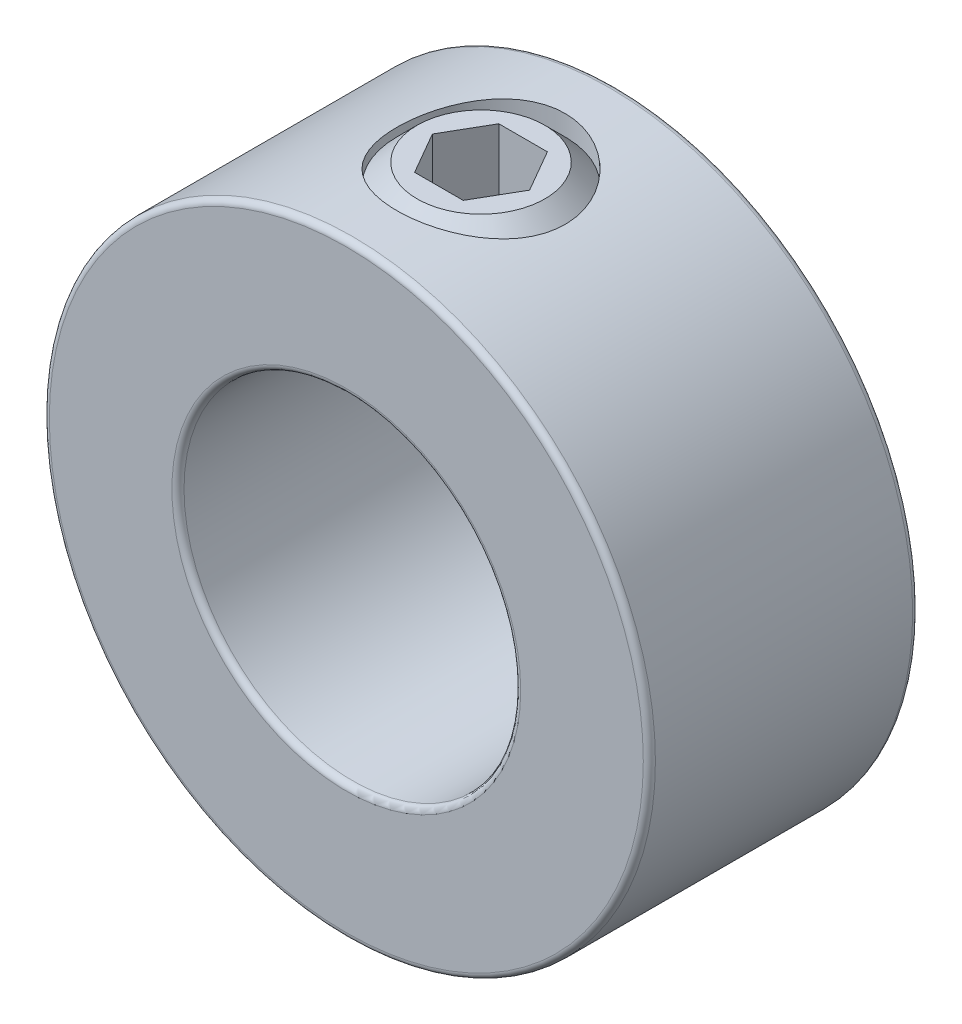
from build123d import *

# Parameters (mm, degrees)
SKETCH1_R          = 14.2875
SKETCH1_R_2        = 7.9375
EXTRUDE1_DEPTH     = 6.35
SKETCH2_R          = 3.96875
CUT_EXTRUDE1_DEPTH = 15.2875
FILLET1_R          = 0.28575
CUT_EXTRUDE2_DEPTH = 3.96875


with BuildPart() as part:
    # Sketch1 → Extrude1 (new body, symmetric)
    with BuildSketch(Plane.XY):
        Circle(SKETCH1_R)
        Circle(SKETCH1_R_2, mode=Mode.SUBTRACT)
    extrude(amount=EXTRUDE1_DEPTH, both=True)

    # Sketch2 → Cut-Extrude1 (cut, through all)
    with BuildSketch(Plane(origin=(41.275, 0, 0), x_dir=(0, 0, -1), z_dir=(0, -1, 0))):
        with Locations((0, -41.275)):
            Circle(SKETCH2_R)
    extrude(amount=-CUT_EXTRUDE1_DEPTH, mode=Mode.SUBTRACT)

    # Fillet1
    fillet1_edges = [part.edges().sort_by_distance(p)[0] for p in [
        (-14.2875, 0, -6.35),
        (-14.2875, 0, 6.35),
        (-7.9375, 0, -6.35),
        (-7.9375, 0, 6.35),
    ]]
    fillet(fillet1_edges, radius=FILLET1_R)


with BuildPart() as body_2:
    # Sketch3 → Revolve1 (revolve)
    with BuildSketch(Plane.XY):
        Polygon((-3.010240789, 7.9375), (-1.150211053, 7.9375), (0, 9.087711053), (0, 14.2875), (-3.010240789, 14.2875), (-3.96875, 13.328990789), (-3.96875, 8.896009211), align=None)
    revolve(axis=Axis((0, 7.9375, 0), (0, -1, 0)))

    # Sketch4 → Cut-Extrude2 (cut)
    with BuildSketch(Plane(origin=(3.3734375, 14.2875, 0), x_dir=(0, 0, -1), z_dir=(0, -1, 0))):
        Polygon((0, -1.082078619), (-1.984375, -2.22775806), (-1.984375, -4.51911694), (0, -5.664796381), (1.984375, -4.51911694), (1.984375, -2.22775806), align=None)
    extrude(amount=CUT_EXTRUDE2_DEPTH, mode=Mode.SUBTRACT)


solid = Compound([part.part, body_2.part])
